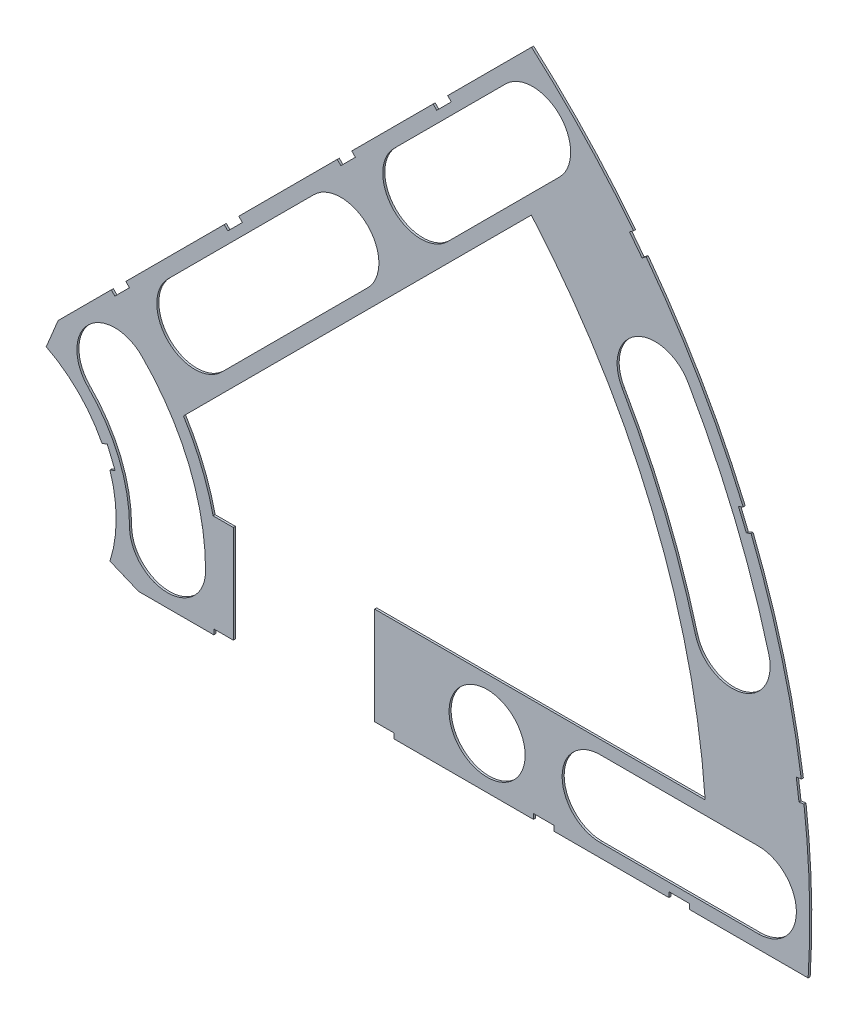
from build123d import *

# Parameters (mm, degrees)
BOSS_EXTRUDE1_DEPTH = 0.254
SKETCH2_R           = 4.699
CUT_EXTRUDE1_DEPTH  = 1.254
SKETCH3_W           = 2.54
SKETCH3_H           = 0.635
CUT_EXTRUDE2_DEPTH  = 1.254
CUT_EXTRUDE4_DEPTH  = 1.254
SKETCH5_W           = 17.4625
SKETCH5_H           = 15.24
CUT_EXTRUDE5_DEPTH  = 1.254


with BuildPart() as part:
    # Sketch1 → Boss-Extrude1 (new body)
    with BuildSketch(Plane.XY):
        with BuildLine():
            Line((67.21146711, 76.191723231), (8.696654013, 17.676910134))
            Line((8.696654013, 17.676910134), (7.228954972, 14.133571205))
            ThreePointArc((7.228954972, 14.133571205), (14.666587579, 6.075099489), (15.105587123, -4.88230096))
            Line((15.105587123, -4.88230096), (18.648926052, -6.35))
            Line((18.648926052, -6.35), (101.401368334, -6.35))
            ThreePointArc((101.401368334, -6.35), (93.866160503, 38.880636728), (67.21146711, 76.191723231))
        make_face()
        with BuildLine():
            Line((88.672924278, 6.35), (27.86051193, 6.35))
            ThreePointArc((27.86051193, 6.35), (26.399857642, 10.93517908), (24.190484974, 15.210228852))
            Line((24.190484974, 15.210228852), (67.191354125, 58.211098004))
            ThreePointArc((67.191354125, 58.211098004), (82.13289044, 34.020557137), (88.672924278, 6.35))
        make_face(mode=Mode.SUBTRACT)
    extrude(amount=BOSS_EXTRUDE1_DEPTH)

    # Sketch2 → Cut-Extrude1 (cut, through all)
    with BuildSketch(Plane.XY.offset(0.254)):
        with Locations((22.225, 0)):
            Circle(SKETCH2_R)
        with Locations((36.195, 0)):
            Circle(SKETCH2_R)
        with Locations((61.722, 0)):
            Circle(SKETCH2_R)
        with Locations((75.692, 0)):
            Circle(SKETCH2_R)
        with Locations((95.25, 0)):
            Circle(SKETCH2_R)
        with Locations((15.715448212, 15.715448212)):
            Circle(SKETCH2_R)
        with Locations((25.593729945, 25.593729945)):
            Circle(SKETCH2_R)
        with Locations((43.644044748, 43.644044748)):
            Circle(SKETCH2_R)
        with Locations((53.522326482, 53.522326482)):
            Circle(SKETCH2_R)
        with Locations((92.004434954, 24.652514046)):
            Circle(SKETCH2_R)
        with Locations((82.48891971, 47.625)):
            Circle(SKETCH2_R)
        with Locations((67.351920908, 67.351920908)):
            Circle(SKETCH2_R)
    extrude(amount=-CUT_EXTRUDE1_DEPTH, mode=Mode.SUBTRACT)

    # Sketch3 → Cut-Extrude2 (cut, through all)
    with BuildSketch(Plane.XY.offset(0.254)):
        Polygon((15.266435406, 24.246691527), (17.06248663, 26.042742751), (17.511499436, 25.593729945), (15.715448212, 23.797678721), align=None)
        Polygon((44.991083167, 53.971339288), (43.195031942, 52.175288063), (43.644044748, 51.726275257), (45.440095973, 53.522326482), align=None)
        with Locations((29.21, -6.0325)):
            Rectangle(SKETCH3_W, SKETCH3_H)
        with Locations((68.707, -6.0325)):
            Rectangle(SKETCH3_W, SKETCH3_H)
        Polygon((29.230733674, 38.210989795), (31.026784898, 40.007041019), (31.475797704, 39.558028213), (29.67974648, 37.761976989), align=None)
        Polygon((56.845021246, 65.825277367), (55.048970022, 64.029226143), (55.497982828, 63.580213337), (57.294034052, 65.376264561), align=None)
        with Locations((48.9585, -6.0325)):
            Rectangle(SKETCH3_W, SKETCH3_H)
        with Locations((85.471, -6.0325)):
            Rectangle(SKETCH3_W, SKETCH3_H)
        Polygon((99.935462164, 14.437711971), (100.266998693, 11.919442024), (101.526133667, 12.085210288), (101.194597138, 14.603480236), align=None)
        Polygon((93.765504959, 37.464305742), (94.938831965, 37.950313702), (93.966816047, 40.296967714), (92.793489041, 39.810959755), align=None)
        Polygon((79.327792988, 62.471156422), (80.874047017, 60.456038938), (81.88160576, 61.229165953), (80.33535173, 63.244283437), align=None)
        Polygon((13.593916116, 7.005422516), (14.565932035, 4.658768503), (15.739259041, 5.144776462), (14.767243123, 7.491430475), align=None)
    extrude(amount=-CUT_EXTRUDE2_DEPTH, mode=Mode.SUBTRACT)

    # Sketch6 → Cut-Extrude4 (cut, through all)
    with BuildSketch(Plane.XY.offset(0.254)):
        with BuildLine():
            Line((22.27103518, 28.91642471), (40.321349984, 46.966739513))
            ThreePointArc((40.321349984, 46.966739513), (46.966739513, 46.966739513), (46.966739513, 40.321349984))
            Line((46.966739513, 40.321349984), (28.91642471, 22.27103518))
            ThreePointArc((28.91642471, 22.27103518), (22.27103518, 22.27103518), (22.27103518, 28.91642471))
        make_face()
        with BuildLine():
            Line((50.199631717, 56.845021246), (64.029226143, 70.674615673))
            ThreePointArc((64.029226143, 70.674615673), (70.674615673, 70.674615673), (70.674615673, 64.029226143))
            Line((70.674615673, 64.029226143), (56.845021246, 50.199631717))
            ThreePointArc((56.845021246, 50.199631717), (50.199631717, 50.199631717), (50.199631717, 56.845021246))
        make_face()
        with BuildLine():
            Line((95.25, -4.699), (75.692, -4.699))
            ThreePointArc((75.692, -4.699), (70.993, 0), (75.692, 4.699))
            Line((75.692, 4.699), (95.25, 4.699))
            ThreePointArc((95.25, 4.699), (99.949, 0), (95.25, -4.699))
        make_face()
        with BuildLine():
            ThreePointArc((26.924, 0), (24.874532533, 10.303368733), (19.038142977, 19.038142977))
            ThreePointArc((19.038142977, 19.038142977), (12.392753447, 19.038142977), (12.392753447, 12.392753447))
            ThreePointArc((12.392753447, 12.392753447), (16.191912687, 6.706909836), (17.526, 0))
            ThreePointArc((17.526, 0), (22.225, -4.699), (26.924, 0))
        make_face()
        with BuildLine():
            ThreePointArc((96.543320412, 25.868704739), (92.340835395, 38.248826381), (86.558373083, 49.9745))
            ThreePointArc((86.558373083, 49.9745), (80.13941971, 51.694453372), (78.419466338, 45.2755))
            ThreePointArc((78.419466338, 45.2755), (83.658215548, 34.652367484), (87.465549496, 23.436323353))
            ThreePointArc((87.465549496, 23.436323353), (93.220625647, 20.113628588), (96.543320412, 25.868704739))
        make_face()
    extrude(amount=-CUT_EXTRUDE4_DEPTH, mode=Mode.SUBTRACT)

    # Sketch5 → Cut-Extrude5 (cut, through all)
    with BuildSketch(Plane.XY.offset(0.254)):
        with Locations((39.08425, 0)):
            Rectangle(SKETCH5_W, SKETCH5_H)
    extrude(amount=-CUT_EXTRUDE5_DEPTH, mode=Mode.SUBTRACT)


solid = part.part
